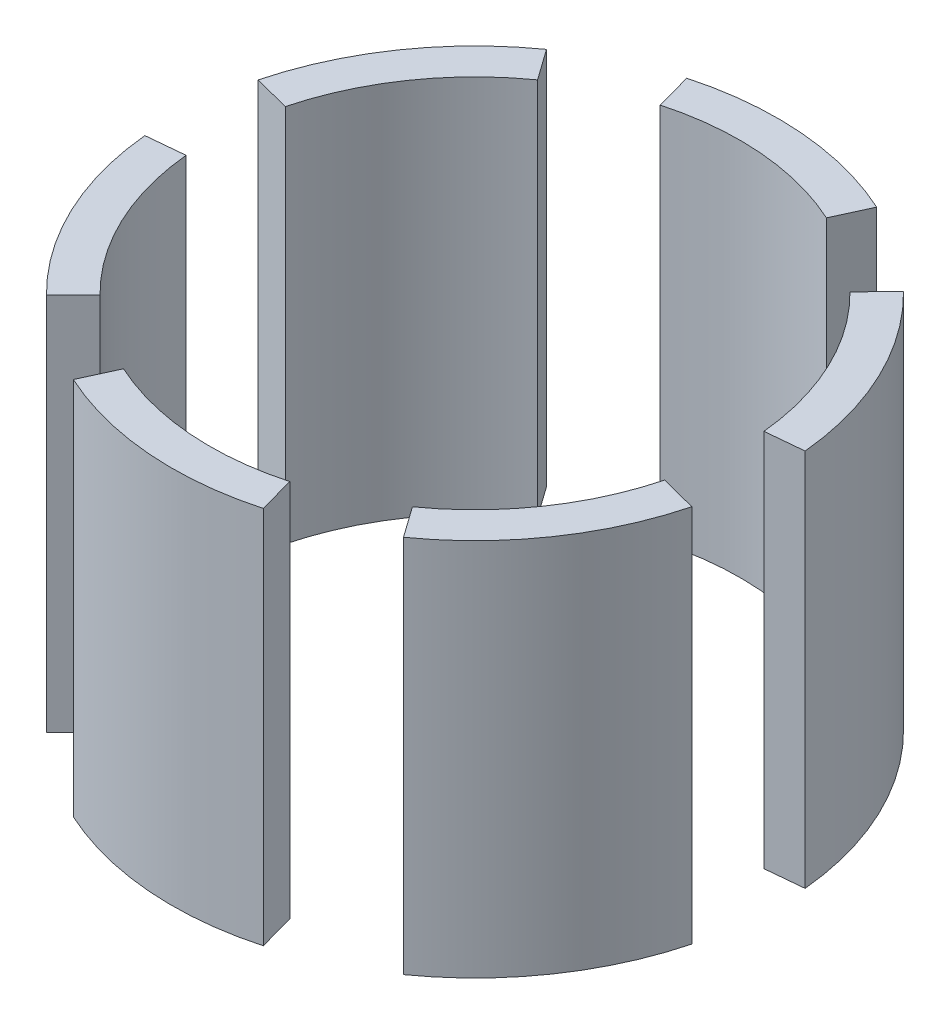
from build123d import *

# Parameters (mm, degrees)
BOSS_EXTRUDE2_DEPTH   = 25
BOSS_EXTRUDE2_2_DEPTH = 25
BOSS_EXTRUDE2_3_DEPTH = 25
BOSS_EXTRUDE2_4_DEPTH = 25
BOSS_EXTRUDE2_5_DEPTH = 25
BOSS_EXTRUDE2_6_DEPTH = 25
SKETCH7_R             = 17.5
CUT_EXTRUDE1_DEPTH    = 25


with BuildPart() as part:
    # Sketch6 → Boss-Extrude2 (new body)
    with BuildSketch(Plane(origin=(0, 0, 0), x_dir=(1, 0, 0), z_dir=(0, 1, 0))):
        with BuildLine():
            ThreePointArc((-19.353791735, 5.042890586), (-16.461845117, 11.358153694), (-11.584357027, 16.303455839))
            Line((-11.584357027, 16.303455839), (0, 0))
            Line((0, 0), (-19.353791735, 5.042890586))
        make_face()
    extrude(amount=BOSS_EXTRUDE2_DEPTH)


with BuildPart() as body_2:
    # Sketch6 → Boss-Extrude2 2 (new body)
    with BuildSketch(Plane(origin=(0, 0, 0), x_dir=(1, 0, 0), z_dir=(0, 1, 0))):
        with BuildLine():
            ThreePointArc((-14.044167224, -14.239430009), (-18.067372198, -8.577299217), (-19.911385439, -1.880619552))
            Line((-19.911385439, -1.880619552), (0, 0))
            Line((0, 0), (-14.044167224, -14.239430009))
        make_face()
    extrude(amount=BOSS_EXTRUDE2_2_DEPTH)


with BuildPart() as body_3:
    # Sketch6 → Boss-Extrude2 3 (new body)
    with BuildSketch(Plane(origin=(0, 0, 0), x_dir=(1, 0, 0), z_dir=(0, 1, 0))):
        with BuildLine():
            ThreePointArc((5.309624512, -19.282320595), (-1.605527081, -19.935452912), (-8.327028412, -18.184075391))
            Line((-8.327028412, -18.184075391), (0, 0))
            Line((0, 0), (5.309624512, -19.282320595))
        make_face()
    extrude(amount=BOSS_EXTRUDE2_3_DEPTH)


with BuildPart() as body_4:
    # Sketch6 → Boss-Extrude2 4 (new body)
    with BuildSketch(Plane(origin=(0, 0, 0), x_dir=(1, 0, 0), z_dir=(0, 1, 0))):
        with BuildLine():
            ThreePointArc((19.353791735, -5.042890586), (16.461845117, -11.358153694), (11.584357027, -16.303455839))
            Line((11.584357027, -16.303455839), (0, 0))
            Line((0, 0), (19.353791735, -5.042890586))
        make_face()
    extrude(amount=BOSS_EXTRUDE2_4_DEPTH)


with BuildPart() as body_5:
    # Sketch6 → Boss-Extrude2 5 (new body)
    with BuildSketch(Plane(origin=(0, 0, 0), x_dir=(1, 0, 0), z_dir=(0, 1, 0))):
        with BuildLine():
            ThreePointArc((14.044167224, 14.239430009), (18.067372198, 8.577299217), (19.911385439, 1.880619552))
            Line((19.911385439, 1.880619552), (0, 0))
            Line((0, 0), (14.044167224, 14.239430009))
        make_face()
    extrude(amount=BOSS_EXTRUDE2_5_DEPTH)


with BuildPart() as body_6:
    # Sketch6 → Boss-Extrude2 6 (new body)
    with BuildSketch(Plane(origin=(0, 0, 0), x_dir=(1, 0, 0), z_dir=(0, 1, 0))):
        with BuildLine():
            ThreePointArc((-5.309624512, 19.282320595), (1.605527081, 19.935452912), (8.327028412, 18.184075391))
            Line((8.327028412, 18.184075391), (0, 0))
            Line((0, 0), (-5.309624512, 19.282320595))
        make_face()
    extrude(amount=BOSS_EXTRUDE2_6_DEPTH)


with BuildPart() as cut_extrude1_tool:
    # Sketch7 → Cut-Extrude1 (new body)
    with BuildSketch(Plane(origin=(0, 0, 0), x_dir=(1, 0, 0), z_dir=(0, 1, 0))):
        Circle(SKETCH7_R)
    extrude(amount=CUT_EXTRUDE1_DEPTH)


with BuildPart() as part_1:
    add(part.part)

    # Cut-Extrude1: cut by cut_extrude1_tool
    add(cut_extrude1_tool.part, mode=Mode.SUBTRACT)


with BuildPart() as body_2_1:
    add(body_2.part)

    # Cut-Extrude1: cut by cut_extrude1_tool
    add(cut_extrude1_tool.part, mode=Mode.SUBTRACT)


with BuildPart() as body_3_1:
    add(body_3.part)

    # Cut-Extrude1: cut by cut_extrude1_tool
    add(cut_extrude1_tool.part, mode=Mode.SUBTRACT)


with BuildPart() as body_4_1:
    add(body_4.part)

    # Cut-Extrude1: cut by cut_extrude1_tool
    add(cut_extrude1_tool.part, mode=Mode.SUBTRACT)


with BuildPart() as body_5_1:
    add(body_5.part)

    # Cut-Extrude1: cut by cut_extrude1_tool
    add(cut_extrude1_tool.part, mode=Mode.SUBTRACT)


with BuildPart() as body_6_1:
    add(body_6.part)

    # Cut-Extrude1: cut by cut_extrude1_tool
    add(cut_extrude1_tool.part, mode=Mode.SUBTRACT)


solid = Compound([part_1.part, body_2_1.part, body_3_1.part, body_4_1.part, body_5_1.part, body_6_1.part])
